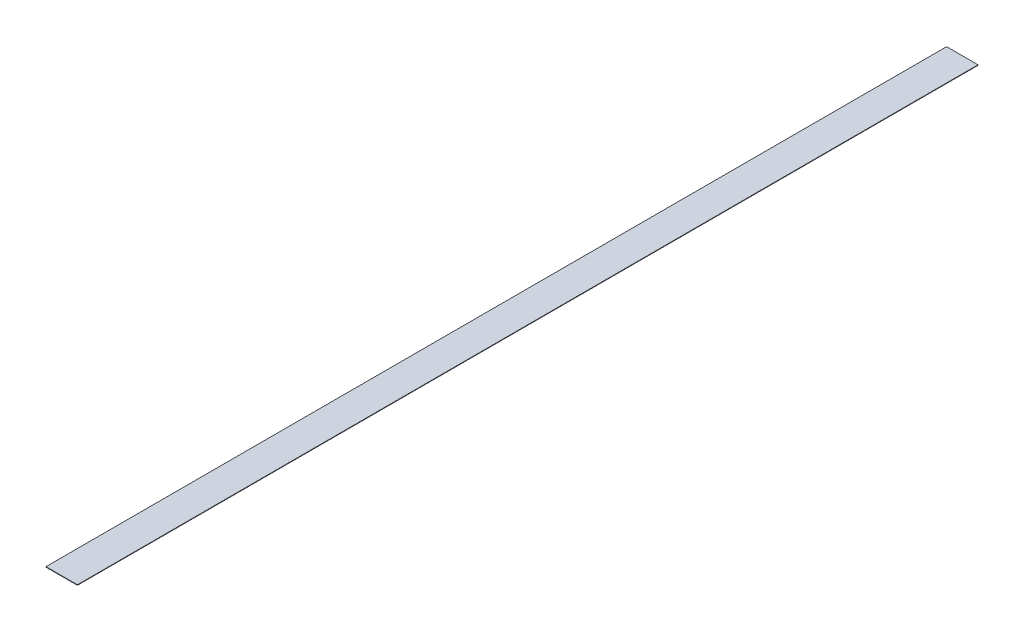
from build123d import *

# Parameters (mm, degrees)
SKETCH1_W           = 50.8
SKETCH1_H           = 1457.325
BOSS_EXTRUDE1_DEPTH = 0.79375


with BuildPart() as part:
    # Sketch1 → Boss-Extrude1 (new body)
    with BuildSketch(Plane(origin=(0, 0, 0), x_dir=(1, 0, 0), z_dir=(0, 1, 0))):
        Rectangle(SKETCH1_W, SKETCH1_H)
    extrude(amount=BOSS_EXTRUDE1_DEPTH)


solid = part.part
